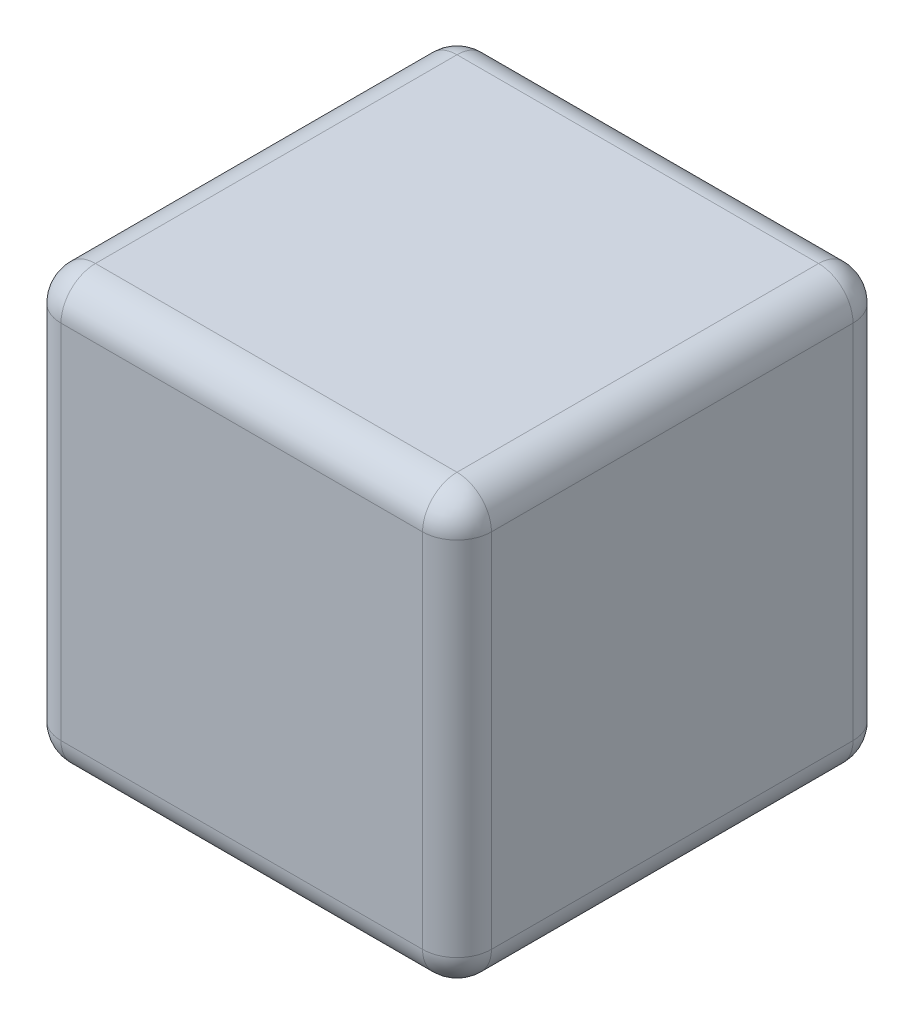
from build123d import *

# Parameters (mm, degrees)
SKETCH1_W           = 31.75
SKETCH1_H           = 31.75
BOSS_EXTRUDE1_DEPTH = 31.75
FILLET2_R           = 2.54


with BuildPart() as part:
    # Sketch1 → Boss-Extrude1 (new body)
    with BuildSketch(Plane(origin=(0, 0, 0), x_dir=(1, 0, 0), z_dir=(0, 1, 0))):
        with Locations((15.875, 15.875)):
            Rectangle(SKETCH1_W, SKETCH1_H)
    extrude(amount=BOSS_EXTRUDE1_DEPTH)

    # Fillet2
    fillet2_edges = [part.edges().sort_by_distance(p)[0] for p in [
        (15.875, 31.75, -31.75),
        (0, 31.75, -15.875),
        (15.875, 31.75, 0),
        (0, 0, -15.875),
        (15.875, 0, -31.75),
        (31.75, 0, -15.875),
        (15.875, 0, 0),
        (0, 15.875, 0),
        (0, 15.875, -31.75),
        (31.75, 15.875, -31.75),
        (31.75, 15.875, 0),
        (31.75, 31.75, -15.875),
    ]]
    fillet(fillet2_edges, radius=FILLET2_R)


solid = part.part
